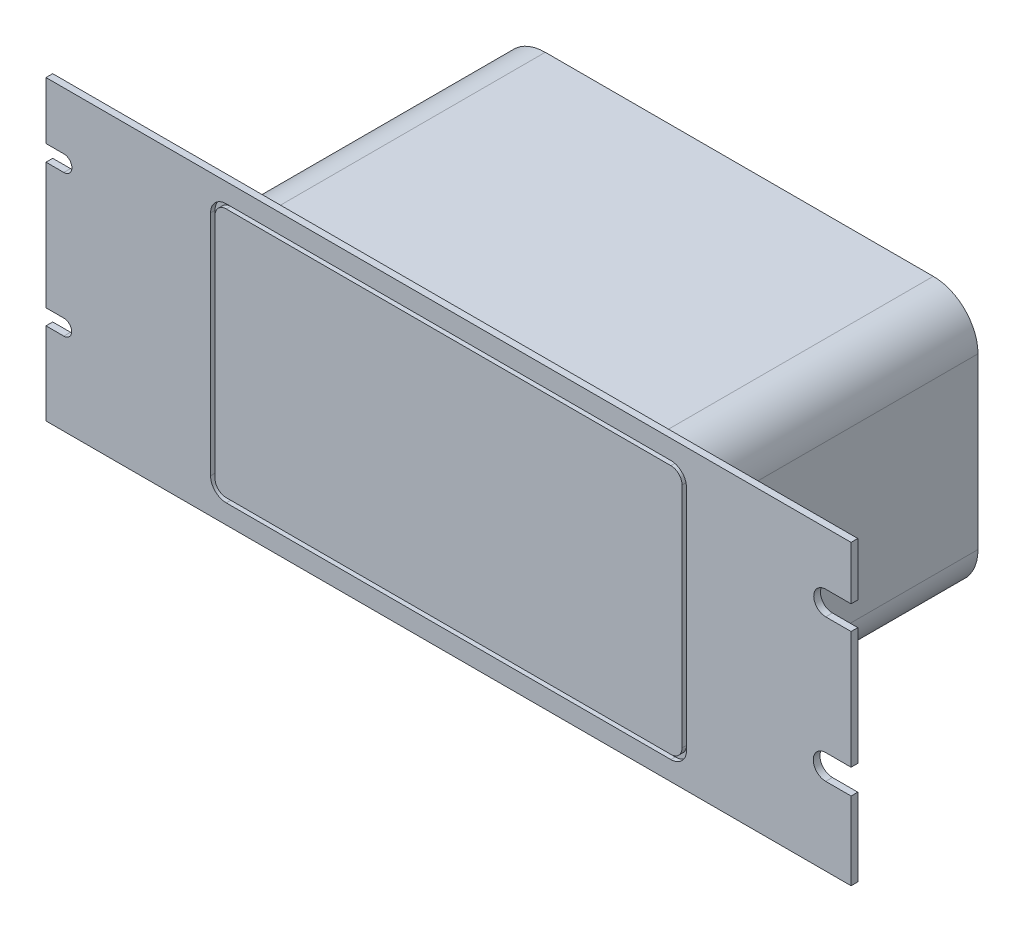
from build123d import *

# Parameters (mm, degrees)
SALIENTE_EXTRUIR1_DEPTH = 3
SALIENTE_EXTRUIR2_DEPTH = 130
CORTAR_EXTRUIR1_DEPTH   = 2
CORTAR_EXTRUIR2_DEPTH   = 29


with BuildPart() as part:
    # Croquis1 → Saliente-Extruir1 (new body)
    with BuildSketch(Plane.XY):
        Polygon((-180, 59.5), (-180, 66.5), (-173, 66.5), (173, 66.5), (180, 66.5), (180, 59.5), (180, -59.5), (180, -66.5), (173, -66.5), (-173, -66.5), (-180, -66.5), (-180, -59.5), align=None)
        with BuildLine():
            Line((-86.752968629, 57.900573009), (86.752968629, 57.900573009))
            ThreePointArc((86.752968629, 57.900573009), (100.895104253, 52.042708633), (106.752968629, 37.900573009))
            Line((106.752968629, 37.900573009), (106.752968629, -37.900573009))
            ThreePointArc((106.752968629, -37.900573009), (100.895104253, -52.042708633), (86.752968629, -57.900573009))
            Line((86.752968629, -57.900573009), (-86.752968629, -57.900573009))
            ThreePointArc((-86.752968629, -57.900573009), (-100.895104253, -52.042708633), (-106.752968629, -37.900573009))
            Line((-106.752968629, -37.900573009), (-106.752968629, 37.900573009))
            ThreePointArc((-106.752968629, 37.900573009), (-100.895104253, 52.042708633), (-86.752968629, 57.900573009))
        make_face(mode=Mode.SUBTRACT)
    extrude(amount=SALIENTE_EXTRUIR1_DEPTH)

    # Croquis2 → Saliente-Extruir2 (add)
    with BuildSketch(Plane.XY.offset(3)):
        with BuildLine():
            Line((-106.752968629, 37.900573009), (-106.752968629, -37.900573009))
            ThreePointArc((-106.752968629, -37.900573009), (-100.895104253, -52.042708633), (-86.752968629, -57.900573009))
            Line((-86.752968629, -57.900573009), (86.752968629, -57.900573009))
            ThreePointArc((86.752968629, -57.900573009), (100.895104253, -52.042708633), (106.752968629, -37.900573009))
            Line((106.752968629, -37.900573009), (106.752968629, 37.900573009))
            ThreePointArc((106.752968629, 37.900573009), (100.895104253, 52.042708633), (86.752968629, 57.900573009))
            Line((86.752968629, 57.900573009), (-86.752968629, 57.900573009))
            ThreePointArc((-86.752968629, 57.900573009), (-100.895104253, 52.042708633), (-106.752968629, 37.900573009))
        make_face()
    extrude(amount=-SALIENTE_EXTRUIR2_DEPTH)

    # Croquis3 → Cortar-Extruir1 (cut)
    with BuildSketch(Plane.XY.offset(3)):
        with BuildLine():
            Line((99.412909993, -57.909788035), (-99.412909993, -57.909788035))
            ThreePointArc((-99.412909993, -57.909788035), (-104.362657461, -55.859535503), (-106.412909993, -50.909788035))
            Line((-106.412909993, -50.909788035), (-106.412909993, 50.909788035))
            ThreePointArc((-106.412909993, 50.909788035), (-104.362657461, 55.859535503), (-99.412909993, 57.909788035))
            Line((-99.412909993, 57.909788035), (99.412909993, 57.909788035))
            ThreePointArc((99.412909993, 57.909788035), (104.362657461, 55.859535503), (106.412909993, 50.909788035))
            Line((106.412909993, 50.909788035), (106.412909993, -50.909788035))
            ThreePointArc((106.412909993, -50.909788035), (104.362657461, -55.859535503), (99.412909993, -57.909788035))
        make_face()
        with BuildLine():
            Line((-104.412909993, -50.909788035), (-104.412909993, 50.909788035))
            ThreePointArc((-104.412909993, 50.909788035), (-102.948443899, 54.445321941), (-99.412909993, 55.909788035))
            Line((-99.412909993, 55.909788035), (99.412909993, 55.909788035))
            ThreePointArc((99.412909993, 55.909788035), (102.948443899, 54.445321941), (104.412909993, 50.909788035))
            Line((104.412909993, 50.909788035), (104.412909993, -50.909788035))
            ThreePointArc((104.412909993, -50.909788035), (102.948443899, -54.445321941), (99.412909993, -55.909788035))
            Line((99.412909993, -55.909788035), (-99.412909993, -55.909788035))
            ThreePointArc((-99.412909993, -55.909788035), (-102.948443899, -54.445321941), (-104.412909993, -50.909788035))
        make_face(mode=Mode.SUBTRACT)
    extrude(amount=-CORTAR_EXTRUIR1_DEPTH, mode=Mode.SUBTRACT)

    # Croquis4 → Cortar-Extruir2 (cut)
    with BuildSketch(Plane.XY.offset(3)):
        with BuildLine():
            Line((-180, 40.936641428), (-172.017039574, 40.936641428))
            ThreePointArc((-172.017039574, 40.936641428), (-168.413104138, 37.332705992), (-172.017039574, 33.728770556))
            Line((-172.017039574, 33.728770556), (-180, 33.728770556))
            ThreePointArc((-180, 33.728770556), (-183.603935436, 37.332705992), (-180, 40.936641428))
        make_face()
        with BuildLine():
            Line((-180, -22.678860967), (-172.017039574, -22.678860967))
            ThreePointArc((-172.017039574, -22.678860967), (-168.533610515, -26.162290026), (-172.017039574, -29.645719085))
            Line((-172.017039574, -29.645719085), (-180, -29.645719085))
            ThreePointArc((-180, -29.645719085), (-183.483429059, -26.162290026), (-180, -22.678860967))
        make_face()
        with BuildLine():
            Line((180, 31.976759047), (168.655882601, 31.976759047))
            ThreePointArc((168.655882601, 31.976759047), (163.299935657, 37.332705992), (168.655882601, 42.688652937))
            Line((168.655882601, 42.688652937), (180, 42.688652937))
            ThreePointArc((180, 42.688652937), (185.355946945, 37.332705992), (180, 31.976759047))
        make_face()
        with BuildLine():
            Line((180, -31.731355776), (168.655882601, -31.731355776))
            ThreePointArc((168.655882601, -31.731355776), (163.086816851, -26.162290026), (168.655882601, -20.593224276))
            Line((168.655882601, -20.593224276), (180, -20.593224276))
            ThreePointArc((180, -20.593224276), (185.56906575, -26.162290026), (180, -31.731355776))
        make_face()
    extrude(amount=-CORTAR_EXTRUIR2_DEPTH, mode=Mode.SUBTRACT)


solid = part.part
